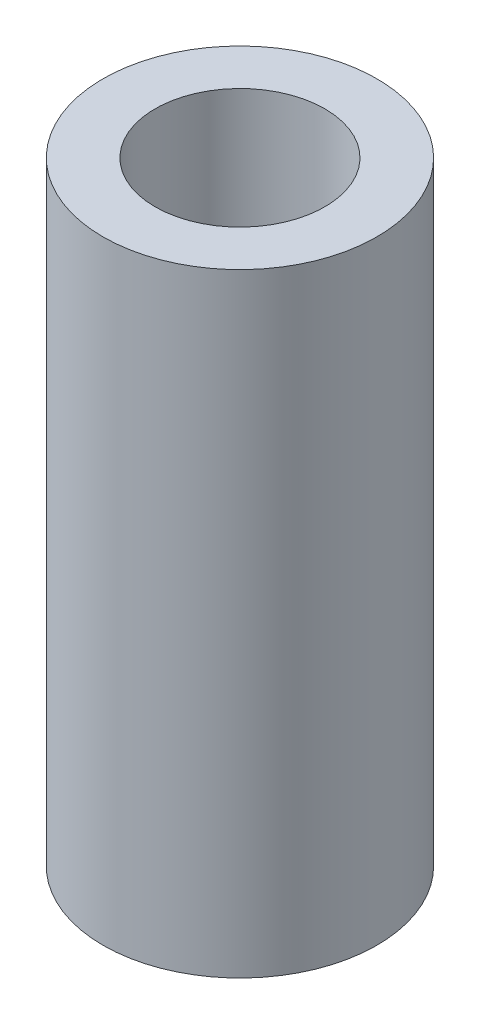
from build123d import *

# Parameters (mm, degrees)
ESQUISSE1_R      = 12.5
ESQUISSE1_R_2    = 7.75
EXTRUSION1_DEPTH = 56


with BuildPart() as part:
    # Esquisse1 → Extrusion1 (new body)
    with BuildSketch(Plane(origin=(0, 0, 0), x_dir=(1, 0, 0), z_dir=(0, 1, 0))):
        Circle(ESQUISSE1_R)
        Circle(ESQUISSE1_R_2, mode=Mode.SUBTRACT)
    extrude(amount=EXTRUSION1_DEPTH)


solid = part.part
